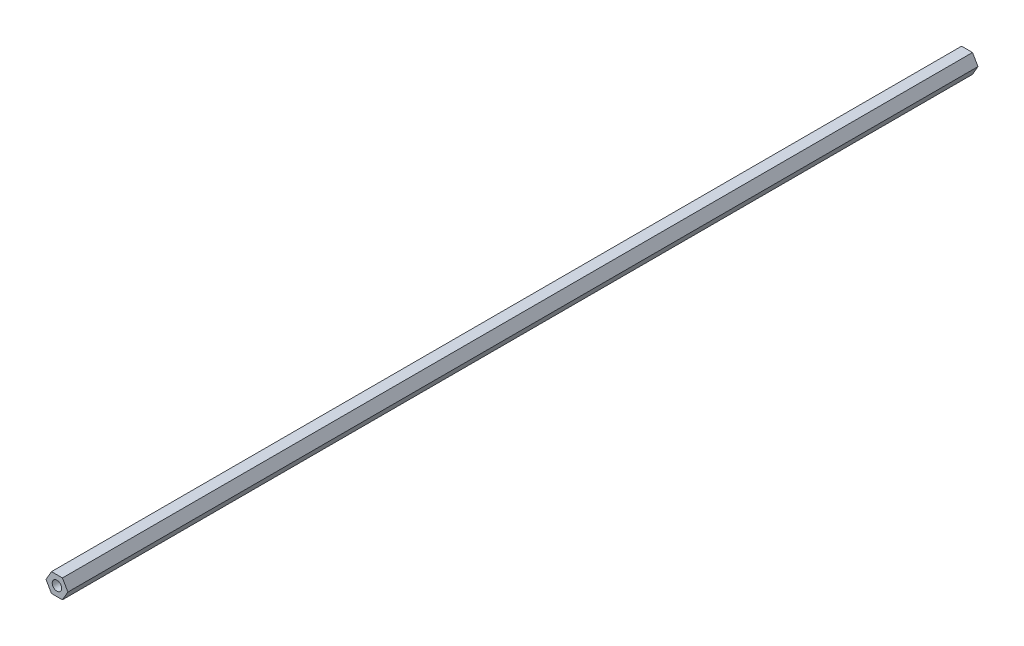
from build123d import *

# Parameters (mm, degrees)
SKETCH1_R           = 3.175
BOSS_EXTRUDE1_DEPTH = 609.6


with BuildPart() as part:
    # Sketch1 → Boss-Extrude1 (new body)
    with BuildSketch(Plane.XY):
        Polygon((-3.666174209, 6.35), (-7.332348419, 0), (-3.666174209, -6.35), (3.666174209, -6.35), (7.332348419, 0), (3.666174209, 6.35), align=None)
        Circle(SKETCH1_R, mode=Mode.SUBTRACT)
    extrude(amount=BOSS_EXTRUDE1_DEPTH)


solid = part.part
